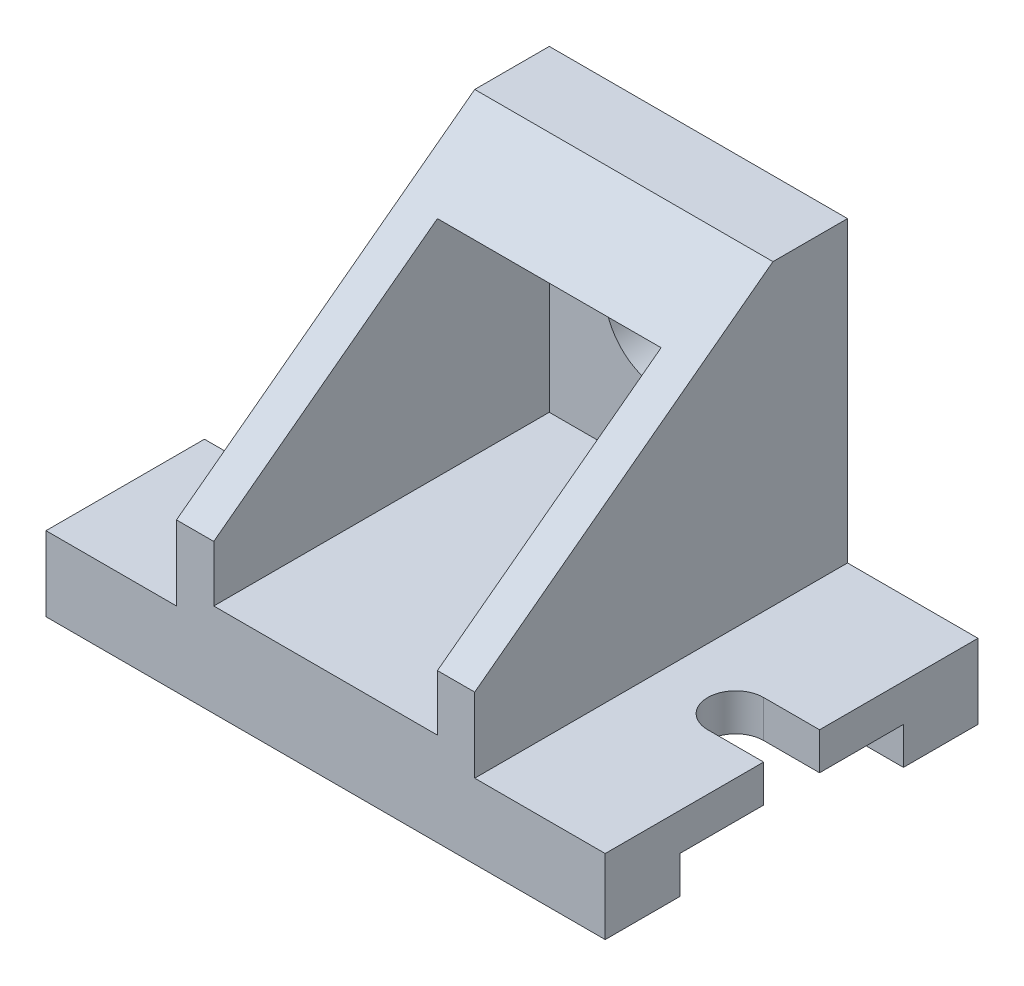
from build123d import *

# Parameters (mm, degrees)
SKETCH1_W           = 150
SKETCH1_H           = 100
BOSS_EXTRUDE1_DEPTH = 20
SKETCH2_W           = 60
SKETCH2_H           = 10
CUT_EXTRUDE1_DEPTH  = 151
CUT_EXTRUDE2_DEPTH  = 20
BOSS_EXTRUDE3_DEPTH = 40
SKETCH10_W          = 60
SKETCH10_H          = 60
CUT_EXTRUDE3_DEPTH  = 90
SKETCH11_R          = 15
CUT_EXTRUDE4_DEPTH  = 90


with BuildPart() as part:
    # Sketch1 → Boss-Extrude1 (new body)
    with BuildSketch(Plane(origin=(0, 0, 0), x_dir=(1, 0, 0), z_dir=(0, 1, 0))):
        Rectangle(SKETCH1_W, SKETCH1_H)
    extrude(amount=BOSS_EXTRUDE1_DEPTH)

    # Sketch2 → Cut-Extrude1 (cut, through all)
    with BuildSketch(Plane.ZY.offset(75)):
        with Locations((0, 5)):
            Rectangle(SKETCH2_W, SKETCH2_H)
    extrude(amount=-CUT_EXTRUDE1_DEPTH, mode=Mode.SUBTRACT)

    # Sketch3 → Cut-Extrude2 (cut)
    with BuildSketch(Plane(origin=(0, 20, 0), x_dir=(1, 0, 0), z_dir=(0, 1, 0))):
        with BuildLine():
            Line((-75, 7.5), (-75, -7.5))
            Line((-75, -7.5), (-60, -7.5))
            ThreePointArc((-60, -7.5), (-52.5, 0), (-60, 7.5))
            Line((-60, 7.5), (-75, 7.5))
        make_face()
        with BuildLine():
            Line((75, 7.5), (75, -7.5))
            Line((75, -7.5), (60, -7.5))
            ThreePointArc((60, -7.5), (52.5, 0), (60, 7.5))
            Line((60, 7.5), (75, 7.5))
        make_face()
    extrude(amount=-CUT_EXTRUDE2_DEPTH, mode=Mode.SUBTRACT)

    # Sketch8 → Boss-Extrude3 (add, symmetric)
    with BuildSketch(Plane(origin=(0, 0, 0), x_dir=(0, 0, -1), z_dir=(1, 0, 0))):
        Polygon((50, 20), (50, 100), (30, 100), (-50, 40), (-50, 20), align=None)
    extrude(amount=BOSS_EXTRUDE3_DEPTH, both=True)

    # Sketch10 → Cut-Extrude3 (cut)
    with BuildSketch(Plane.XY.offset(50)):
        with Locations((0, 55)):
            Rectangle(SKETCH10_W, SKETCH10_H)
    extrude(amount=-CUT_EXTRUDE3_DEPTH, mode=Mode.SUBTRACT)

    # Sketch11 → Cut-Extrude4 (cut)
    with BuildSketch(Plane(origin=(0, 0, -50), x_dir=(-1, 0, 0), z_dir=(0, 0, -1))):
        with Locations((0, 60)):
            Circle(SKETCH11_R)
    extrude(amount=-CUT_EXTRUDE4_DEPTH, mode=Mode.SUBTRACT)


solid = part.part
